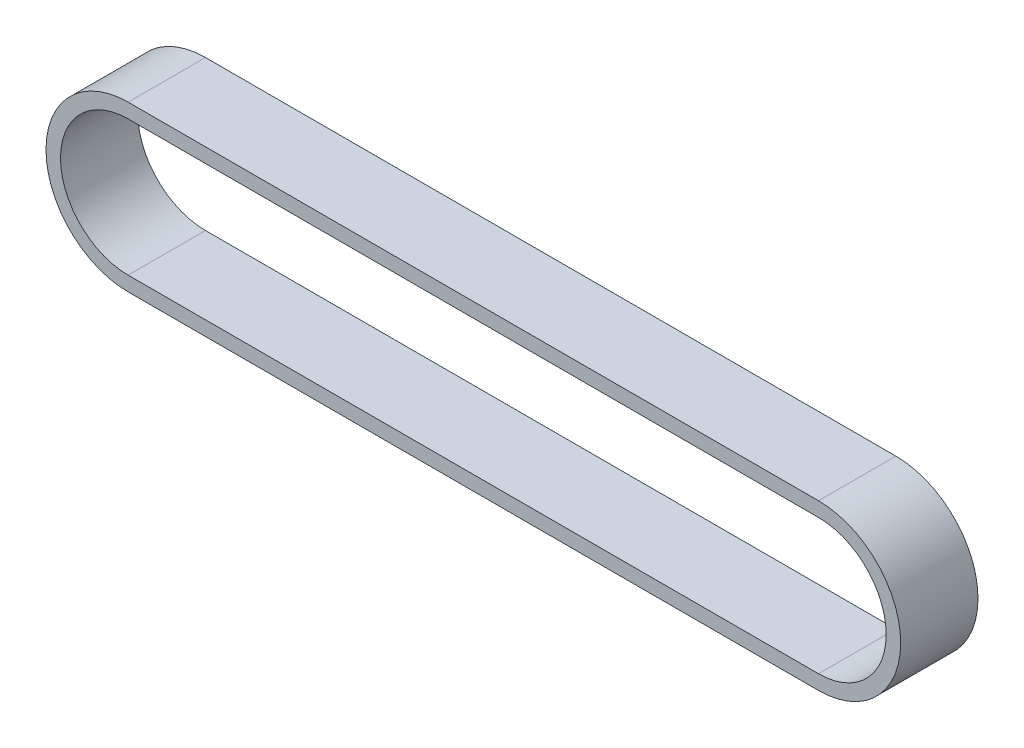
from build123d import *

# Parameters (mm, degrees)
ESTRUSIONE_ESTRUSIONE1_DEPTH = 6.4


with BuildPart() as part:
    # Schizzo1 (on Front Plane) → Estrusione-Estrusione1 (new body)
    with BuildSketch(Plane.XY):
        with BuildLine():
            Line((0, -6.8), (-57.140178509, -6.8))
            ThreePointArc((-57.140178509, -6.8), (-63.940178509, 0), (-57.140178509, 6.8))
            Line((-57.140178509, 6.8), (0, 6.8))
            ThreePointArc((0, 6.8), (6.8, 0), (0, -6.8))
        make_face()
        with BuildLine():
            Line((0, -5.6), (-57.140178509, -5.6))
            ThreePointArc((-57.140178509, -5.6), (-62.740178509, 0), (-57.140178509, 5.6))
            Line((-57.140178509, 5.6), (0, 5.6))
            ThreePointArc((0, 5.6), (5.6, 0), (0, -5.6))
        make_face(mode=Mode.SUBTRACT)
    extrude(amount=ESTRUSIONE_ESTRUSIONE1_DEPTH)


solid = part.part
